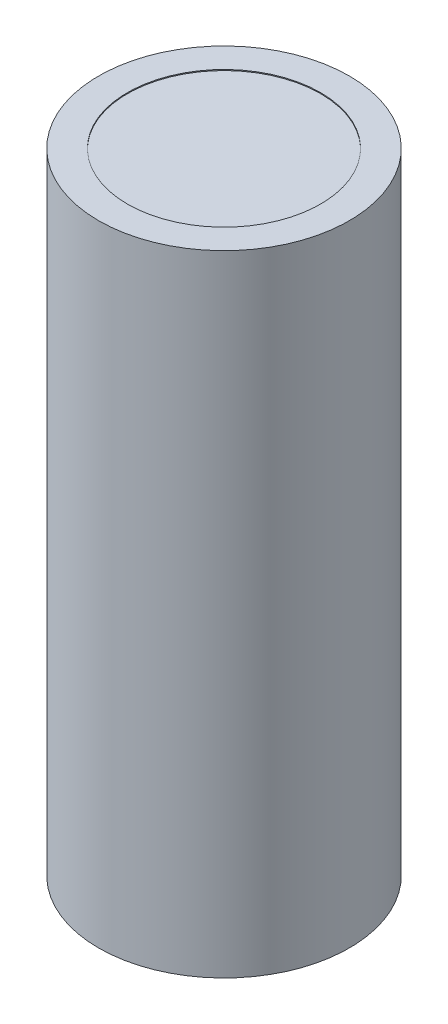
from build123d import *

# Parameters (mm, degrees)
ESQUISSE1_R             = 13.075
BOSS_EXTRU_1_DEPTH      = 65.7
ESQUISSE2_R             = 10.075
ENL_V_MAT_EXTRU_1_DEPTH = 0.1
ESQUISSE3_R             = 8.575
ESQUISSE3_R_2           = 7.075
ENL_V_MAT_EXTRU_2_DEPTH = 2


with BuildPart() as part:
    # Esquisse1 → Boss.-Extru.1 (new body)
    with BuildSketch(Plane(origin=(0, 0, 0), x_dir=(1, 0, 0), z_dir=(0, 1, 0))):
        Circle(ESQUISSE1_R)
    extrude(amount=BOSS_EXTRU_1_DEPTH)

    # Esquisse2 → Enlèv. mat.-Extru.1 (cut)
    with BuildSketch(Plane(origin=(0, 65.7, 0), x_dir=(1, 0, 0), z_dir=(0, 1, 0))):
        Circle(ESQUISSE2_R)
    extrude(amount=-ENL_V_MAT_EXTRU_1_DEPTH, mode=Mode.SUBTRACT)

    # Esquisse3 → Enlèv. mat.-Extru.2 (cut)
    with BuildSketch(Plane.XZ):
        Circle(ESQUISSE3_R)
        Circle(ESQUISSE3_R_2, mode=Mode.SUBTRACT)
    extrude(amount=-ENL_V_MAT_EXTRU_2_DEPTH, mode=Mode.SUBTRACT)


solid = part.part
